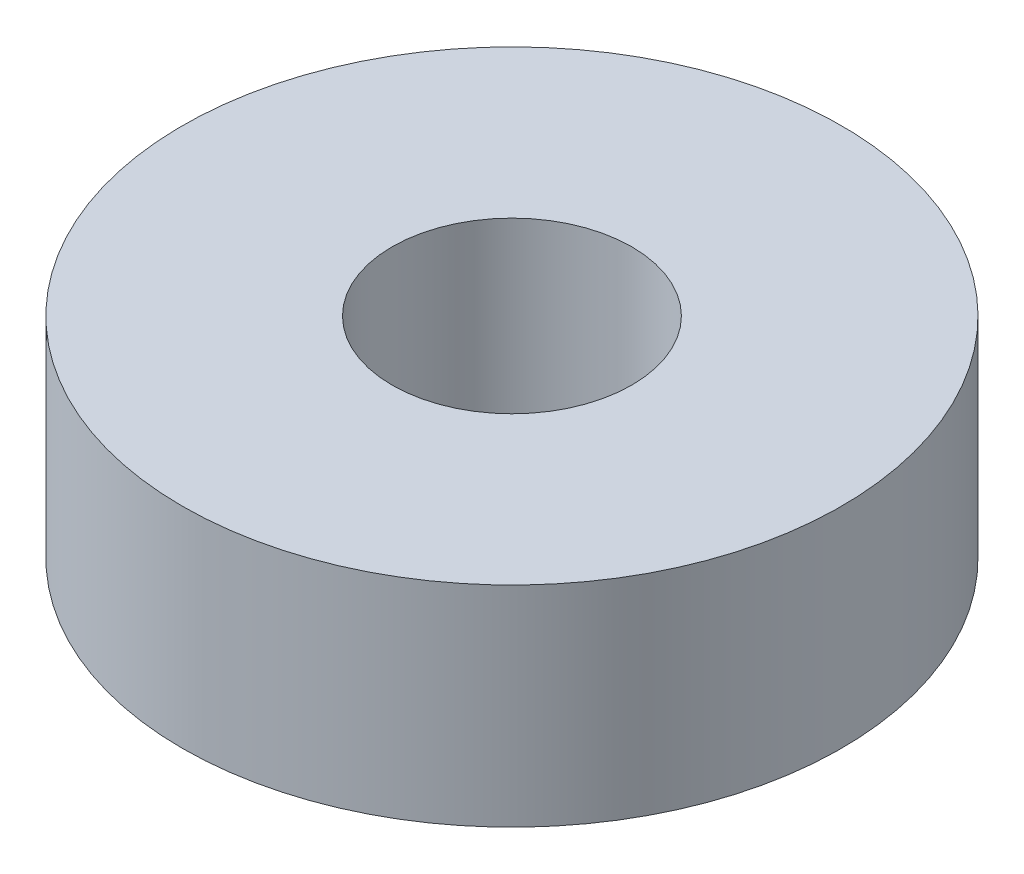
from build123d import *

# Parameters (mm, degrees)
SKETCH1_R           = 11
BOSS_EXTRUDE1_DEPTH = 7
SKETCH2_R           = 4
CUT_EXTRUDE1_DEPTH  = 8


with BuildPart() as part:
    # Sketch1 → Boss-Extrude1 (new body)
    with BuildSketch(Plane(origin=(0, 0, 0), x_dir=(1, 0, 0), z_dir=(0, 1, 0))):
        Circle(SKETCH1_R)
    extrude(amount=BOSS_EXTRUDE1_DEPTH)

    # Sketch2 → Cut-Extrude1 (cut, through all)
    with BuildSketch(Plane(origin=(0, 7, 0), x_dir=(1, 0, 0), z_dir=(0, 1, 0))):
        Circle(SKETCH2_R)
    extrude(amount=-CUT_EXTRUDE1_DEPTH, mode=Mode.SUBTRACT)


solid = part.part
